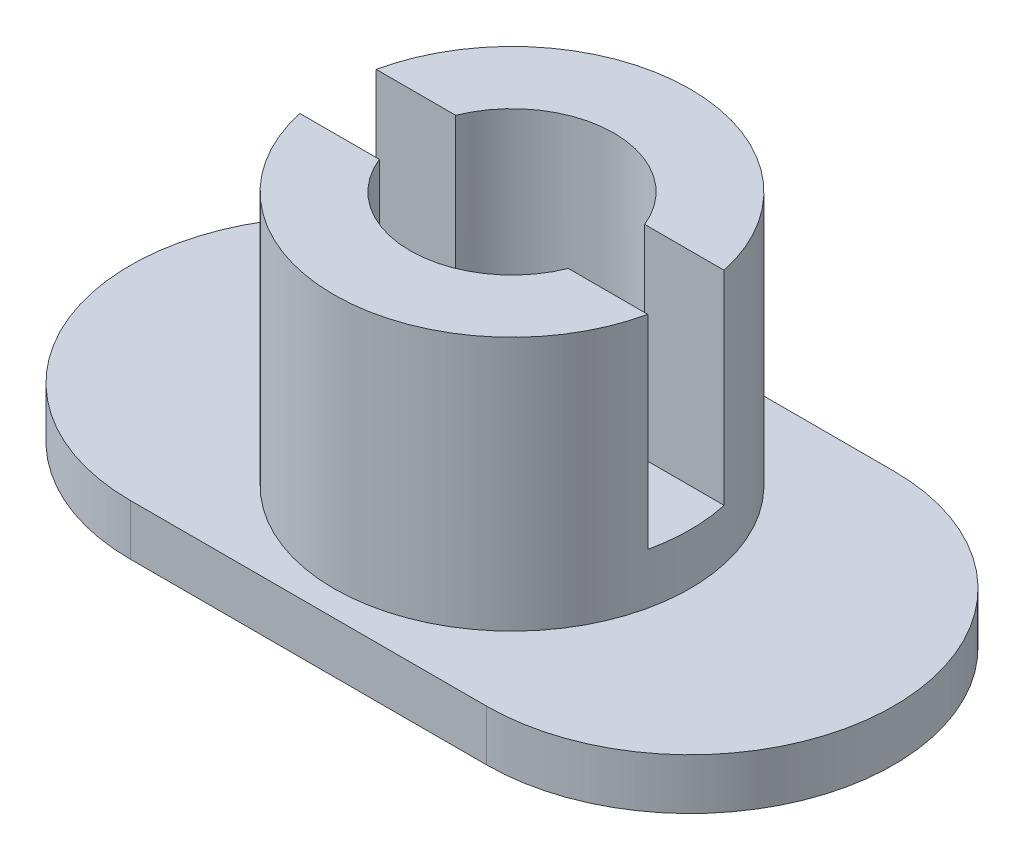
from build123d import *

# Parameters (mm, degrees)
BOSS_EXTRUDE1_DEPTH = 1
SKETCH2_R           = 3.5
BOSS_EXTRUDE2_DEPTH = 5
SKETCH3_R           = 2.0025
CUT_EXTRUDE1_DEPTH  = 7
CUT_EXTRUDE2_DEPTH  = 4


with BuildPart() as part:
    # Sketch1 → Boss-Extrude1 (new body)
    with BuildSketch(Plane(origin=(0, 0, 0), x_dir=(1, 0, 0), z_dir=(0, 1, 0))):
        with BuildLine():
            Line((-3.5, 4), (3.5, 4))
            ThreePointArc((3.5, 4), (7.5, 0), (3.5, -4))
            Line((3.5, -4), (-3.5, -4))
            ThreePointArc((-3.5, -4), (-7.5, 0), (-3.5, 4))
        make_face()
    extrude(amount=BOSS_EXTRUDE1_DEPTH)

    # Sketch2 → Boss-Extrude2 (add)
    with BuildSketch(Plane(origin=(0, 1, 0), x_dir=(1, 0, 0), z_dir=(0, 1, 0))):
        Circle(SKETCH2_R)
    extrude(amount=BOSS_EXTRUDE2_DEPTH)

    # Sketch3 → Cut-Extrude1 (cut, through all)
    with BuildSketch(Plane(origin=(0, 6, 0), x_dir=(1, 0, 0), z_dir=(0, 1, 0))):
        Circle(SKETCH3_R)
    extrude(amount=-CUT_EXTRUDE1_DEPTH, mode=Mode.SUBTRACT)

    # Sketch4 → Cut-Extrude2 (cut)
    with BuildSketch(Plane(origin=(0, 6, 0), x_dir=(1, 0, 0), z_dir=(0, 1, 0))):
        with BuildLine():
            Line((-1.856746146, 0.75), (-3.418698583, 0.75))
            ThreePointArc((-3.418698583, 0.75), (-3.5, 0), (-3.418698583, -0.75))
            Line((-3.418698583, -0.75), (-1.856746146, -0.75))
            ThreePointArc((-1.856746146, -0.75), (-2.0025, 0), (-1.856746146, 0.75))
        make_face()
        with BuildLine():
            ThreePointArc((3.418698583, -0.75), (3.5, 0), (3.418698583, 0.75))
            Line((3.418698583, 0.75), (1.856746146, 0.75))
            ThreePointArc((1.856746146, 0.75), (2.0025, 0), (1.856746146, -0.75))
            Line((1.856746146, -0.75), (3.418698583, -0.75))
        make_face()
    extrude(amount=-CUT_EXTRUDE2_DEPTH, mode=Mode.SUBTRACT)


solid = part.part
